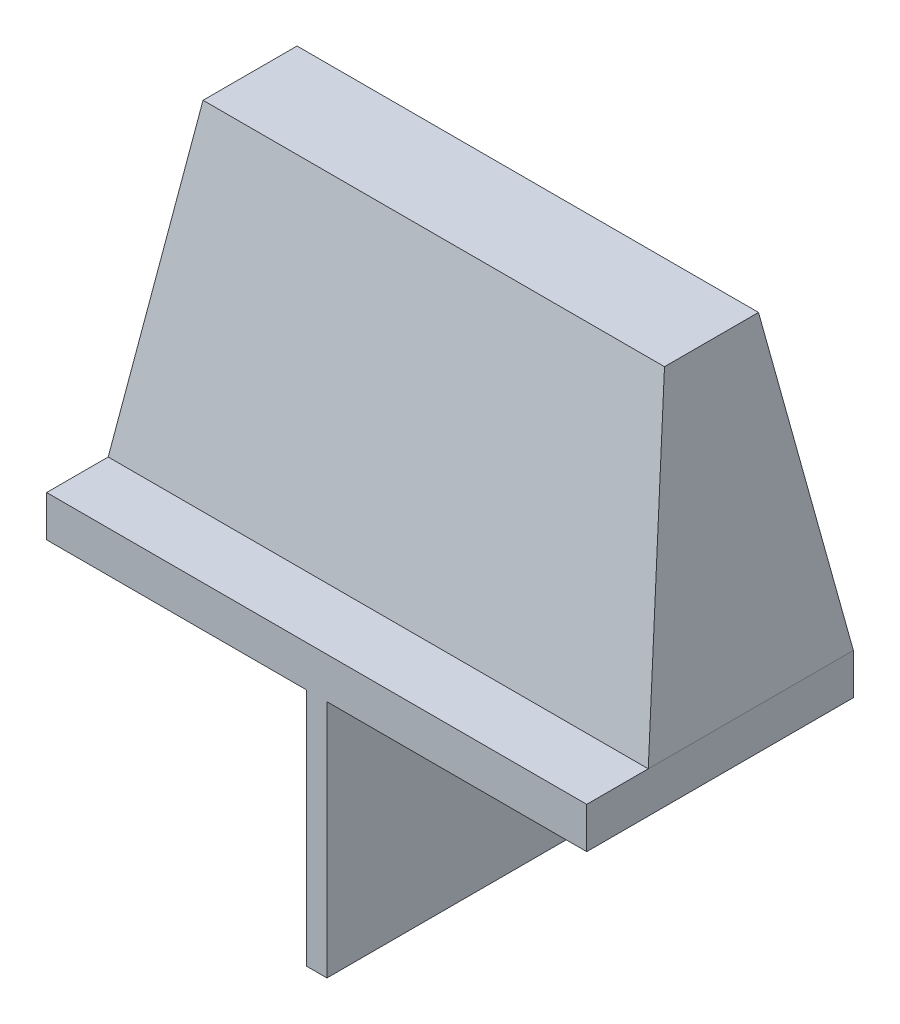
from build123d import *

# Parameters (mm, degrees)
SKETCH2_W           = 40.132
SKETCH2_H           = 19.812
BOSS_EXTRUDE1_DEPTH = 3.048
SKETCH3_W           = 40.132
SKETCH3_H           = 15.24
SKETCH4_W           = 34.29
SKETCH4_H           = 6.985
SKETCH5_W           = 1.524
SKETCH5_H           = 19.812
BOSS_EXTRUDE2_DEPTH = 17.78


with BuildPart() as part:
    # Sketch2 → Boss-Extrude1 (new body)
    with BuildSketch(Plane(origin=(0, 3.048, 0), x_dir=(1, 0, 0), z_dir=(0, 1, 0))):
        with Locations((20.066, 9.906)):
            Rectangle(SKETCH2_W, SKETCH2_H)
    extrude(amount=-BOSS_EXTRUDE1_DEPTH)

    # Sketch3 → Loft1 section 0
    with BuildSketch(Plane(origin=(0, 3.048, 0), x_dir=(1, 0, 0), z_dir=(0, 1, 0))):
        with Locations((20.066, 12.192)):
            Rectangle(SKETCH3_W, SKETCH3_H)
    # Sketch4 → Loft1 section 1
    with BuildSketch(Plane(origin=(0, 25.4, 0), x_dir=(1, 0, 0), z_dir=(0, 1, 0))):
        with Locations((20.066, 12.192)):
            Rectangle(SKETCH4_W, SKETCH4_H)
    loft()

    # Sketch5 → Boss-Extrude2 (add)
    with BuildSketch(Plane(origin=(0, 0, 0), x_dir=(1, 0, 0), z_dir=(0, 1, 0))):
        with Locations((20.066, 9.906)):
            Rectangle(SKETCH5_W, SKETCH5_H)
    extrude(amount=-BOSS_EXTRUDE2_DEPTH)


solid = part.part
